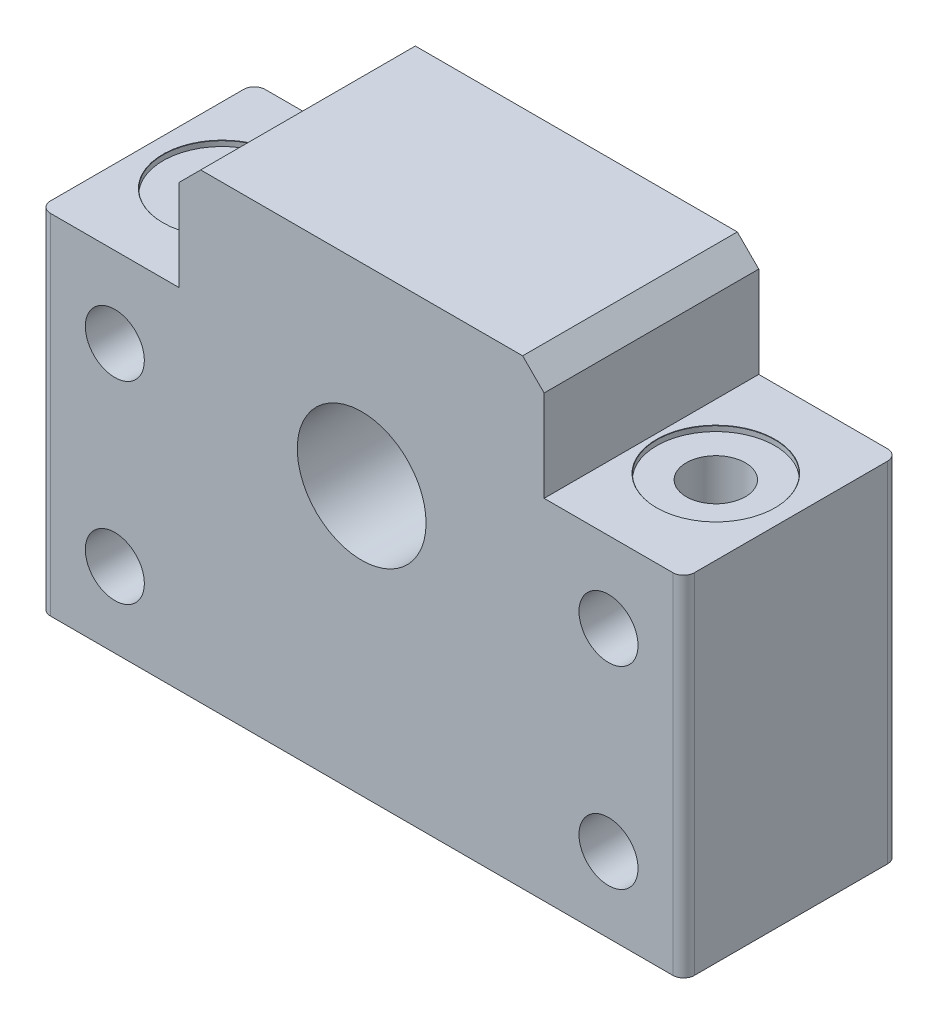
from build123d import *

# Parameters (mm, degrees)
SKETCH_1_R                  = 6
SKETCH_1_R_2                = 2.75
EXTRUDE_1_DEPTH             = 20
CHAMFER_1_SIZE              = 2
FILLET_1_R                  = 1
HOLE_WIZARD_M5_1_AT_2_COUNT = 2
HOLE_WIZARD_M5_1_AT_2_PITCH = 46


with BuildPart() as part:
    # 草图1 → 凸台-拉伸1 (new body)
    with BuildSketch(Plane.XY):
        Polygon((-17, 16.25), (-17, 26.75), (17, 26.75), (17, 16.25), (30, 16.25), (30, -16.25), (-30, -16.25), (-30, 16.25), align=None)
        with Locations((0, 8.75)):
            Circle(SKETCH_1_R, mode=Mode.SUBTRACT)
        with Locations((-23, 8.75)):
            Circle(SKETCH_1_R_2, mode=Mode.SUBTRACT)
        with Locations((-23, -9.25)):
            Circle(SKETCH_1_R_2, mode=Mode.SUBTRACT)
        with Locations((23, -9.25)):
            Circle(SKETCH_1_R_2, mode=Mode.SUBTRACT)
        with Locations((23, 8.75)):
            Circle(SKETCH_1_R_2, mode=Mode.SUBTRACT)
    extrude(amount=EXTRUDE_1_DEPTH)

    # 倒角1
    chamfer_1_edges = [part.edges().sort_by_distance(p)[0] for p in [
        (-17, 26.75, 10),
        (17, 26.75, 10),
    ]]
    chamfer(chamfer_1_edges, length=CHAMFER_1_SIZE)

    # 圆角1
    fillet_1_edges = [part.edges().sort_by_distance(p)[0] for p in [
        (30, 0, 0),
        (-30, 0, 20),
        (30, 0, 20),
        (-30, 0, 0),
    ]]
    fillet(fillet_1_edges, radius=FILLET_1_R)

    # 草图3 → M5 六角头螺栓的柱形沉头孔1 (revolve, cut)
    with BuildSketch(Plane(origin=(23, 16.25, 10), x_dir=(0, 0, 1), z_dir=(1, 0, 0))):
        Polygon((0, 0), (0, 32.5), (2.75, 32.5), (2.75, 0.5), (5.5, 0.5), (5.5, 0.025), (5.525, 0), align=None)
    hole_wizard_m5_1 = revolve(axis=Axis((23, 22.6, 10), (0, -1, 0)), mode=Mode.SUBTRACT)

    # M5 六角头螺栓的柱形沉头孔1 at 2: M5 六角头螺栓的柱形沉头孔1 ×2
    with Locations(*[(-i * HOLE_WIZARD_M5_1_AT_2_PITCH, 0, 0) for i in range(1, HOLE_WIZARD_M5_1_AT_2_COUNT)]):
        add(hole_wizard_m5_1, mode=Mode.SUBTRACT)


solid = part.part
